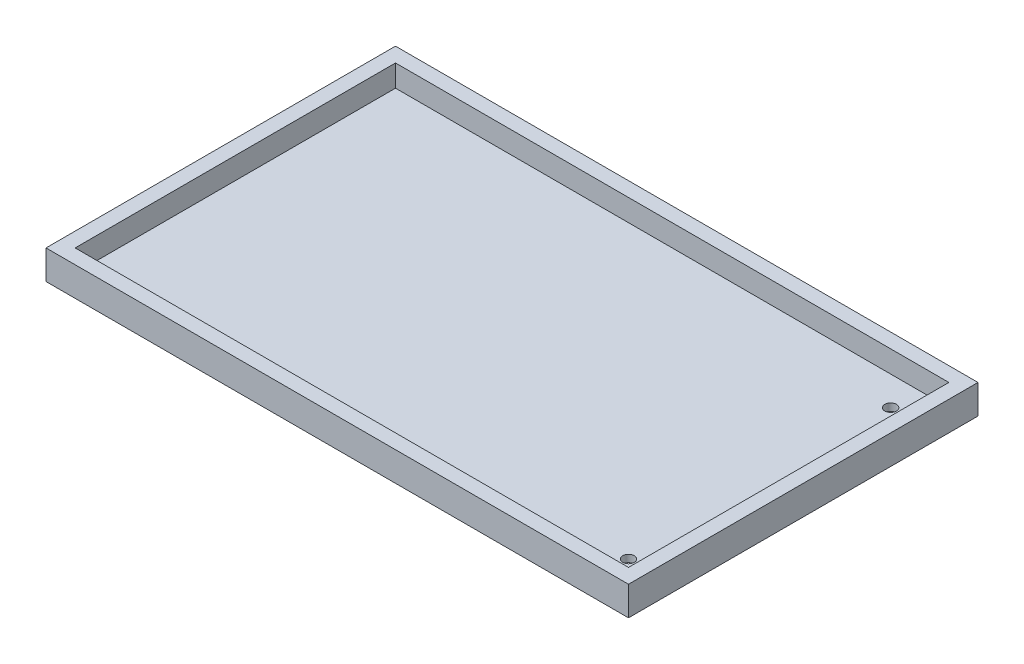
from build123d import *

# Parameters (mm, degrees)
SKETCH1_W           = 101.6
SKETCH1_H           = 60.96
BOSS_EXTRUDE1_DEPTH = 5.08
SKETCH2_W           = 96.52
SKETCH2_H           = 55.88
CUT_EXTRUDE1_DEPTH  = 3.81
SKETCH3_R           = 1.016
CUT_EXTRUDE3_DEPTH  = 11.43


with BuildPart() as part:
    # Sketch1 → Boss-Extrude1 (new body)
    with BuildSketch(Plane(origin=(-10.826110924, 0, 0), x_dir=(1, 0, 0), z_dir=(0, 1, 0))):
        with Locations((-6.069852941, -5.406838235)):
            Rectangle(SKETCH1_W, SKETCH1_H)
    extrude(amount=BOSS_EXTRUDE1_DEPTH)

    # Sketch2 → Cut-Extrude1 (cut)
    with BuildSketch(Plane(origin=(-10.826110924, 5.08, -21.022149646), x_dir=(1, 0, 0), z_dir=(0, 1, 0))):
        with Locations((-6.069852941, -26.428987881)):
            Rectangle(SKETCH2_W, SKETCH2_H)
    extrude(amount=-CUT_EXTRUDE1_DEPTH, mode=Mode.SUBTRACT)

    # Sketch3 → Cut-Extrude3 (cut)
    with BuildSketch(Plane(origin=(0, 1.27, -21.022149646), x_dir=(1, 0, 0), z_dir=(0, 1, 0))):
        with Locations((26.284036135, -3.568987881)):
            Circle(SKETCH3_R)
        with Locations((26.284036135, -49.288987881)):
            Circle(SKETCH3_R)
    extrude(amount=-CUT_EXTRUDE3_DEPTH, mode=Mode.SUBTRACT)


solid = part.part
